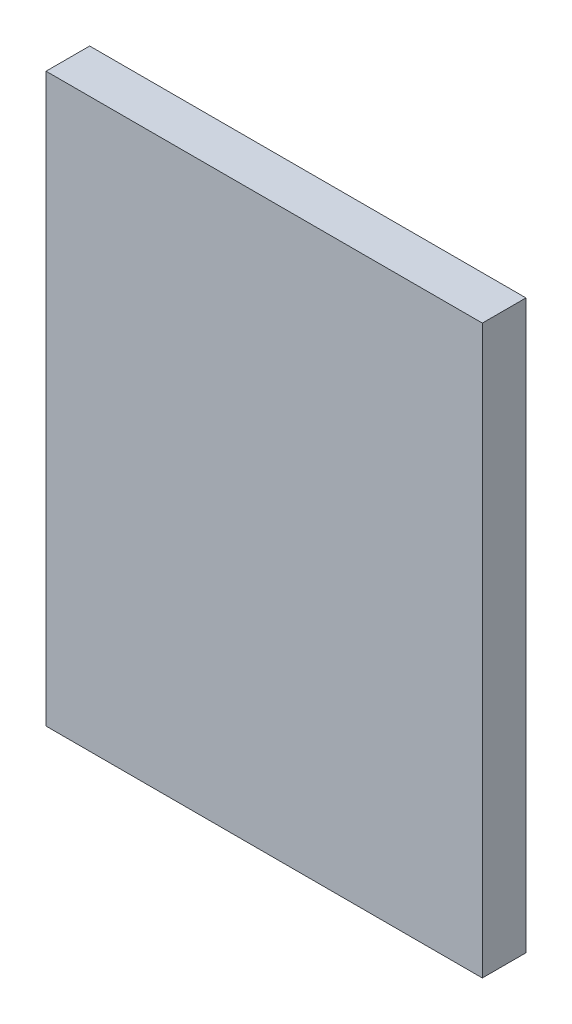
from build123d import *

# Parameters (mm, degrees)
SKETCH1_W           = 190.5
SKETCH1_H           = 247.65
BOSS_EXTRUDE1_DEPTH = 19.05


with BuildPart() as part:
    # Sketch1 → Boss-Extrude1 (new body)
    with BuildSketch(Plane.XY):
        Rectangle(SKETCH1_W, SKETCH1_H)
    extrude(amount=BOSS_EXTRUDE1_DEPTH)


solid = part.part
